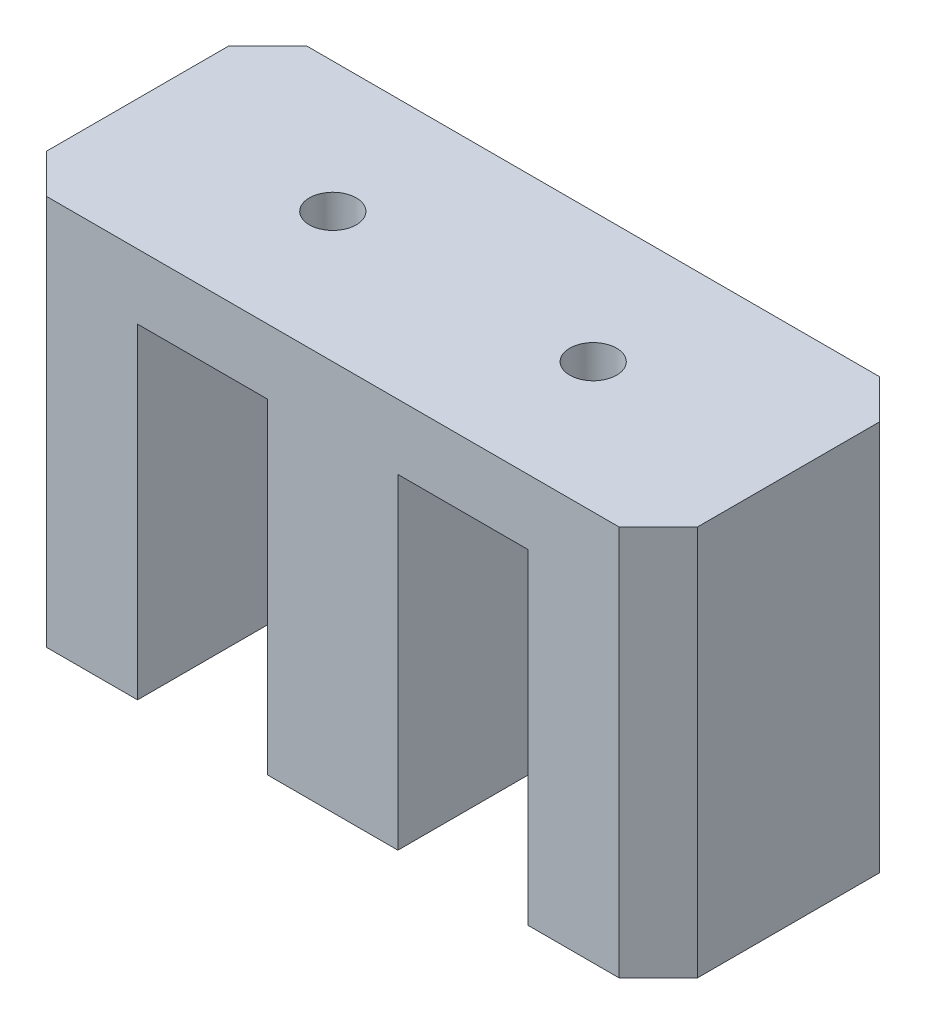
from build123d import *

# Parameters (mm, degrees)
SKIZZE1_W                       = 50
SKIZZE1_H                       = 20
AUFSATZ_LINEAR_AUSTRAGEN1_DEPTH = 30
SKIZZE2_W                       = 10
SKIZZE2_H                       = 20
SCHNITT_LINEAR_AUSTRAGEN1_DEPTH = 25
DURCHGANGSLOCH_F_R_M31_D        = 3.6
FASE1_SIZE                      = 3


with BuildPart() as part:
    # Skizze1 → Aufsatz-Linear austragen1 (new body)
    with BuildSketch(Plane(origin=(0, 0, 0), x_dir=(1, 0, 0), z_dir=(0, 1, 0))):
        Rectangle(SKIZZE1_W, SKIZZE1_H)
    extrude(amount=AUFSATZ_LINEAR_AUSTRAGEN1_DEPTH)

    # Skizze2 → Schnitt-Linear austragen1 (cut)
    with BuildSketch(Plane.XZ):
        with Locations((-10, 0)):
            Rectangle(SKIZZE2_W, SKIZZE2_H)
        with Locations((10, 0)):
            Rectangle(SKIZZE2_W, SKIZZE2_H)
    extrude(amount=-SCHNITT_LINEAR_AUSTRAGEN1_DEPTH, mode=Mode.SUBTRACT)

    # Durchgangsloch für M31 (through all)
    with Locations(Plane(origin=(0, 30, 0), x_dir=(1, 0, 0), z_dir=(0, 1, 0))):
        with Locations((-10, 0), (10, 0)):
            Hole(DURCHGANGSLOCH_F_R_M31_D / 2)

    # Fase1
    fase1_edges = [part.edges().sort_by_distance(p)[0] for p in [
        (-25, 15, -10),
        (25, 15, -10),
        (25, 15, 10),
        (-25, 15, 10),
    ]]
    chamfer(fase1_edges, length=FASE1_SIZE)


solid = part.part
